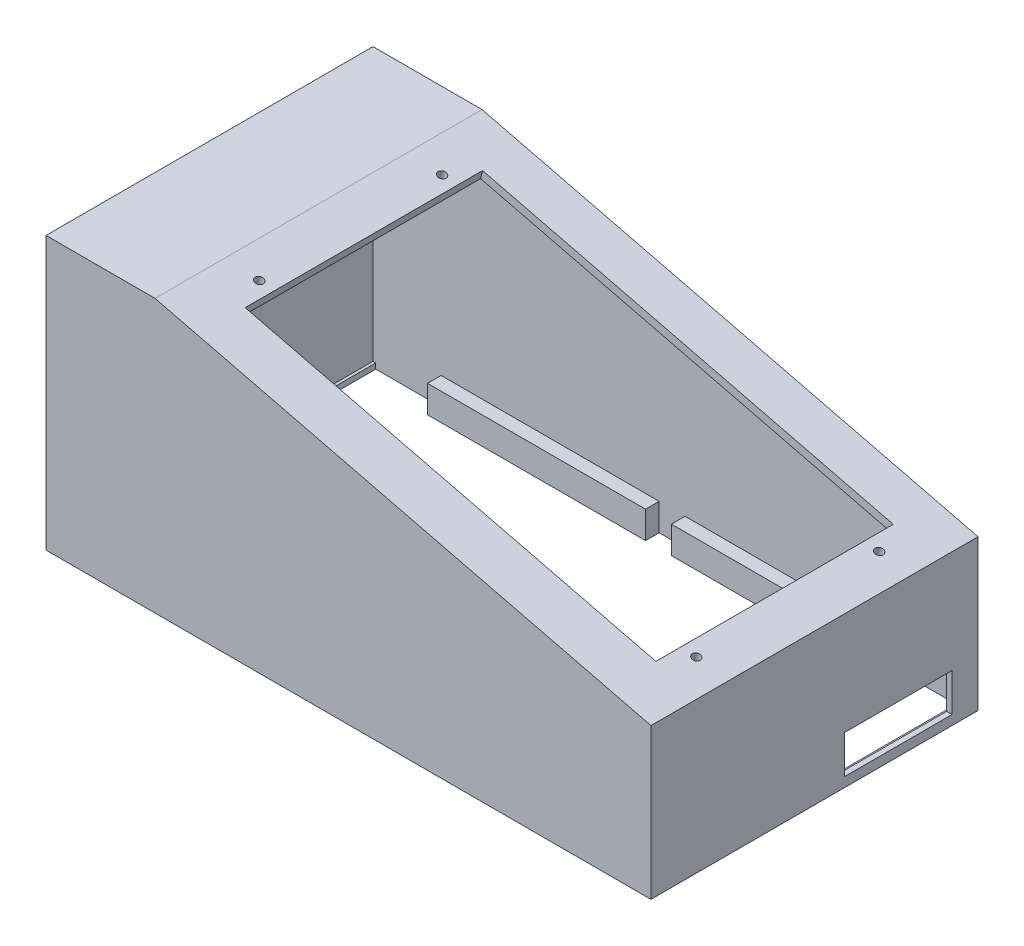
from build123d import *

# Parameters (mm, degrees)
BOSS_EXTRUDE1_DEPTH  = 118
SKETCH2_W            = 68
SKETCH2_H            = 10
BOSS_EXTRUDE2_DEPTH  = 12
SKETCH4_W            = 2
SKETCH4_H            = 5.241203994
BOSS_EXTRUDE4_DEPTH  = 118
SKETCH5_W            = 40
SKETCH5_H            = 14
CUT_EXTRUDE1_DEPTH   = 12
BOSS_EXTRUDE5_START  = -2
SKETCH6_W            = 0.5
SKETCH6_H            = 14
BOSS_EXTRUDE5_DEPTH  = 2
SKETCH7_W            = 118
SKETCH7_H            = 2
BOSS_EXTRUDE6_DEPTH  = 2
SKETCH8_W            = 2
SKETCH8_H            = 0.649840642
BOSS_EXTRUDE7_DEPTH  = 50
BOSS_EXTRUDE8_DEPTH  = 2
SKETCH11_W           = 222
SKETCH11_H           = 2
BOSS_EXTRUDE9_DEPTH  = 2
SKETCH13_W           = 118
SKETCH13_H           = 2
BOSS_EXTRUDE10_DEPTH = 4
SKETCH14_W           = 1
SKETCH14_H           = 46
CUT_EXTRUDE2_DEPTH   = 4
SKETCH15_W           = 215
SKETCH15_H           = 1
CUT_EXTRUDE3_DEPTH   = 4
SKETCH16_W           = 215
SKETCH16_H           = 1
CUT_EXTRUDE4_DEPTH   = 4
SKETCH17_W           = 155.2
SKETCH17_H           = 87.1
CUT_EXTRUDE5_DEPTH   = 4
SKETCH18_W           = 175.2
SKETCH18_H           = 97.1
BOSS_EXTRUDE11_DEPTH = 1
SKETCH19_W           = 155.2
SKETCH19_H           = 87.1
CUT_EXTRUDE6_DEPTH   = 1
SKETCH20_R           = 1.5
CUT_EXTRUDE7_DEPTH   = 47.46373967
SKETCH21_W           = 80
SKETCH21_H           = 10
BOSS_EXTRUDE12_DEPTH = 12
SKETCH22_W           = 80
SKETCH22_H           = 5
CUT_EXTRUDE8_DEPTH   = 12
SKETCH23_W           = 10
SKETCH23_H           = 10
BOSS_EXTRUDE13_DEPTH = 12
BOSS_EXTRUDE14_START = -10
SKETCH24_W           = 12
SKETCH24_H           = 4
BOSS_EXTRUDE14_DEPTH = 10
BOSS_EXTRUDE15_START = -10
SKETCH25_W           = 8
SKETCH25_H           = 1
BOSS_EXTRUDE15_DEPTH = 10
SKETCH27_W           = 80
SKETCH27_H           = 10
BOSS_EXTRUDE16_DEPTH = 5
BOSS_EXTRUDE17_DEPTH = 2
SKETCH30_W           = 80
SKETCH30_H           = 10
BOSS_EXTRUDE18_DEPTH = 10
SKETCH31_W           = 50
SKETCH31_H           = 11.87067785
BOSS_EXTRUDE20_DEPTH = 10
SKETCH32_W           = 50
SKETCH32_H           = 1.87
CUT_EXTRUDE9_DEPTH   = 10


with BuildPart() as part:
    # Sketch1 → Boss-Extrude1 (new body)
    with BuildSketch(Plane.XY):
        Polygon((94.417554234, -32.563143832), (94.417554234, 17.436856168), (-87.582445766, 62.195652174), (-127.582445766, 62.195652174), (-127.582445766, -37.804347826), (-125.582445766, -37.757129772), (-125.582445766, 60.242870228), (-88.016763075, 60.242870228), (92.417554234, 15.869118575), (92.417554234, 15.389638114), (92.417554234, -32.610361886), align=None)
    extrude(amount=BOSS_EXTRUDE1_DEPTH)

    # Sketch2 → Boss-Extrude2 (add)
    with BuildSketch(Plane.ZY.offset(127.582445766)):
        with Locations((84, -32.804347826)):
            Rectangle(SKETCH2_W, SKETCH2_H)
    extrude(amount=-BOSS_EXTRUDE2_DEPTH)

    # Sketch4 → Boss-Extrude4 (add)
    with BuildSketch(Plane.XY.offset(118)):
        with Locations((93.417554234, -35.183745829)):
            Rectangle(SKETCH4_W, SKETCH4_H)
    extrude(amount=-BOSS_EXTRUDE4_DEPTH)

    # Sketch5 → Cut-Extrude1 (cut)
    with BuildSketch(Plane(origin=(94.417554234, 0, 0), x_dir=(0, 0, -1), z_dir=(1, 0, 0))):
        with Locations((-29.5, -27.304347826)):
            Rectangle(SKETCH5_W, SKETCH5_H)
    extrude(amount=-CUT_EXTRUDE1_DEPTH, mode=Mode.SUBTRACT)

    # Sketch6 → Boss-Extrude5 (add)
    with BuildSketch(Plane(origin=(94.417554234, 0, 0), x_dir=(0, 0, -1), z_dir=(1, 0, 0)).offset(BOSS_EXTRUDE5_START)):
        with Locations((-49.25, -27.304347826)):
            Rectangle(SKETCH6_W, SKETCH6_H)
    extrude(amount=BOSS_EXTRUDE5_DEPTH)

    # Sketch7 → Boss-Extrude6 (add)
    with BuildSketch(Plane.ZY.offset(-92.417554234)):
        with Locations((59, -36.804347826)):
            Rectangle(SKETCH7_W, SKETCH7_H)
    extrude(amount=BOSS_EXTRUDE6_DEPTH)

    # Sketch8 → Boss-Extrude7 (add)
    with BuildSketch(Plane(origin=(0, 0, 50), x_dir=(-1, 0, 0), z_dir=(0, 0, -1))):
        with Locations((126.582445766, -37.479427505)):
            Rectangle(SKETCH8_W, SKETCH8_H)
    extrude(amount=BOSS_EXTRUDE7_DEPTH)

    # Sketch10 → Boss-Extrude8 (add)
    with BuildSketch(Plane(origin=(0, 0, 0), x_dir=(-1, 0, 0), z_dir=(0, 0, -1))):
        Polygon((-94.417554234, 17.436856168), (87.582445766, 62.195652174), (127.582445766, 62.195652174), (127.582445766, -37.804347826), (-94.417554234, -37.804347826), align=None)
    extrude(amount=-BOSS_EXTRUDE8_DEPTH)

    # Sketch11 → Boss-Extrude9 (add)
    with BuildSketch(Plane.XY.offset(2)):
        with Locations((-16.582445766, -36.804347826)):
            Rectangle(SKETCH11_W, SKETCH11_H)
    extrude(amount=BOSS_EXTRUDE9_DEPTH)

    # Sketch13 → Boss-Extrude10 (add)
    with BuildSketch(Plane.ZY.offset(127.582445766)):
        with Locations((59, -36.804347826)):
            Rectangle(SKETCH13_W, SKETCH13_H)
    extrude(amount=-BOSS_EXTRUDE10_DEPTH)

    # Sketch14 → Cut-Extrude2 (cut)
    with BuildSketch(Plane(origin=(0, -35.804347826, 0), x_dir=(1, 0, 0), z_dir=(0, 1, 0))):
        with Locations((-124.082445766, -27)):
            Rectangle(SKETCH14_W, SKETCH14_H)
    extrude(amount=-CUT_EXTRUDE2_DEPTH, mode=Mode.SUBTRACT)

    # Sketch15 → Cut-Extrude3 (cut)
    with BuildSketch(Plane.XZ.offset(37.804347826)):
        with Locations((-17.082445766, 3.5)):
            Rectangle(SKETCH15_W, SKETCH15_H)
    extrude(amount=-CUT_EXTRUDE3_DEPTH, mode=Mode.SUBTRACT)

    # Sketch16 → Cut-Extrude4 (cut)
    with BuildSketch(Plane.XZ.offset(37.804347826)):
        with Locations((-17.082445766, 2.5)):
            Rectangle(SKETCH16_W, SKETCH16_H)
    extrude(amount=-CUT_EXTRUDE4_DEPTH, mode=Mode.SUBTRACT)

    # Sketch17 → Cut-Extrude5 (cut)
    with BuildSketch(Plane(origin=(9.428373652, 38.338028676, 0), x_dir=(0.971065881, -0.238811756, 0), z_dir=(0.238811756, 0.971065881, 0))):
        with Locations((-6.191377784, -59)):
            Rectangle(SKETCH17_W, SKETCH17_H)
    extrude(amount=-CUT_EXTRUDE5_DEPTH, mode=Mode.SUBTRACT)

    # Sketch18 → Boss-Extrude11 (add)
    with BuildSketch(Plane(origin=(8.95075014, 36.395896914, 0), x_dir=(0.971065881, -0.238811756, 0), z_dir=(-0.238811756, -0.971065881, 0))):
        with Locations((-6.191377784, 59)):
            Rectangle(SKETCH18_W, SKETCH18_H)
    extrude(amount=BOSS_EXTRUDE11_DEPTH)

    # Sketch19 → Cut-Extrude6 (cut)
    with BuildSketch(Plane(origin=(8.95075014, 36.395896914, 0), x_dir=(0.971065881, -0.238811756, 0), z_dir=(0.238811756, 0.971065881, 0))):
        with Locations((-6.191377784, -59)):
            Rectangle(SKETCH19_W, SKETCH19_H)
    extrude(amount=-CUT_EXTRUDE6_DEPTH, mode=Mode.SUBTRACT)

    # Sketch20 → Cut-Extrude7 (cut, through all)
    with BuildSketch(Plane(origin=(8.711938383, 35.424831033, 0), x_dir=(0.971065881, -0.238811756, 0), z_dir=(-0.238811756, -0.971065881, 0))):
        with Locations((-88.791377784, 92.55)):
            Circle(SKETCH20_R)
        with Locations((-88.791377784, 25.45)):
            Circle(SKETCH20_R)
        with Locations((76.408622216, 25.45)):
            Circle(SKETCH20_R)
        with Locations((76.408622216, 92.55)):
            Circle(SKETCH20_R)
    extrude(amount=-CUT_EXTRUDE7_DEPTH, mode=Mode.SUBTRACT)

    # Sketch21 → Boss-Extrude12 (add)
    with BuildSketch(Plane(origin=(0, 0, 0), x_dir=(-1, 0, 0), z_dir=(0, 0, -1))):
        with Locations((60.582445766, -32.804347826)):
            Rectangle(SKETCH21_W, SKETCH21_H)
    extrude(amount=-BOSS_EXTRUDE12_DEPTH)

    # Sketch22 → Cut-Extrude8 (cut)
    with BuildSketch(Plane.XZ.offset(37.804347826)):
        with Locations((-60.582445766, 9.5)):
            Rectangle(SKETCH22_W, SKETCH22_H)
    extrude(amount=-CUT_EXTRUDE8_DEPTH, mode=Mode.SUBTRACT)

    # Sketch23 → Boss-Extrude13 (add)
    with BuildSketch(Plane(origin=(94.417554234, 0, 0), x_dir=(0, 0, -1), z_dir=(1, 0, 0))):
        with Locations((-61, -32.804347826)):
            Rectangle(SKETCH23_W, SKETCH23_H)
    extrude(amount=-BOSS_EXTRUDE13_DEPTH)

    # Sketch24 → Boss-Extrude14 (add)
    with BuildSketch(Plane.XZ.offset(37.804347826).offset(BOSS_EXTRUDE14_START)):
        with Locations((88.417554234, 54)):
            Rectangle(SKETCH24_W, SKETCH24_H)
    extrude(amount=BOSS_EXTRUDE14_DEPTH)

    # Sketch25 → Boss-Extrude15 (add)
    with BuildSketch(Plane.XZ.offset(37.804347826).offset(BOSS_EXTRUDE15_START)):
        with Locations((86.417554234, 51.5)):
            Rectangle(SKETCH25_W, SKETCH25_H)
    extrude(amount=BOSS_EXTRUDE15_DEPTH)

    # Sketch27 → Boss-Extrude16 (add)
    with BuildSketch(Plane.XY.offset(2)):
        with Locations((28.917554234, -32.804347826)):
            Rectangle(SKETCH27_W, SKETCH27_H)
    extrude(amount=BOSS_EXTRUDE16_DEPTH)

    # Sketch28 → Boss-Extrude17 (add)
    with BuildSketch(Plane.XY.offset(118)):
        Polygon((-127.582445766, -37.804347826), (94.417554234, -37.804347826), (94.417554234, 17.436856168), (-87.582445766, 62.195652174), (-127.582445766, 62.195652174), align=None)
    extrude(amount=BOSS_EXTRUDE17_DEPTH)

    # Sketch30 → Boss-Extrude18 (add)
    with BuildSketch(Plane.XZ.offset(37.804347826)):
        with Locations((-60.582445766, 113)):
            Rectangle(SKETCH30_W, SKETCH30_H)
    extrude(amount=-BOSS_EXTRUDE18_DEPTH)

    # Sketch31 → Boss-Extrude20 (add)
    with BuildSketch(Plane(origin=(0, 0, 118), x_dir=(-1, 0, 0), z_dir=(0, 0, -1))):
        with Locations((-14.417554234, -31.869008901)):
            Rectangle(SKETCH31_W, SKETCH31_H)
    extrude(amount=BOSS_EXTRUDE20_DEPTH)

    # Sketch32 → Cut-Extrude9 (cut)
    with BuildSketch(Plane(origin=(0, 0, 108), x_dir=(-1, 0, 0), z_dir=(0, 0, -1))):
        with Locations((-14.417554234, -26.868669976)):
            Rectangle(SKETCH32_W, SKETCH32_H)
    extrude(amount=-CUT_EXTRUDE9_DEPTH, mode=Mode.SUBTRACT)


solid = part.part
